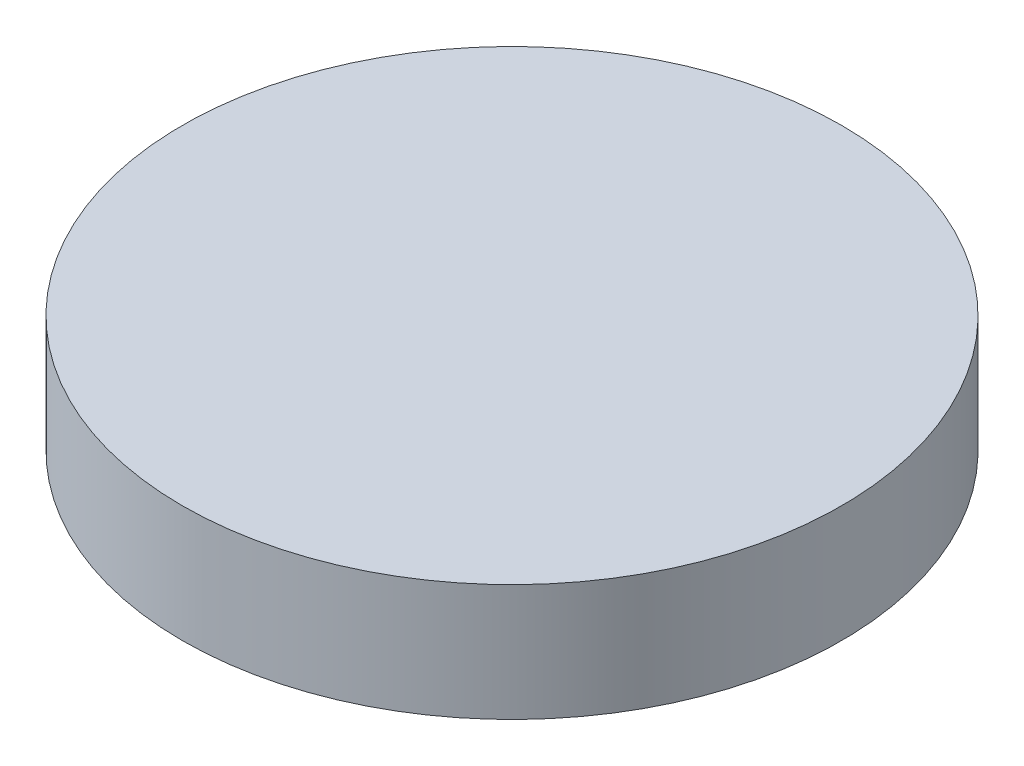
from build123d import *

# Parameters (mm, degrees)
SKETCH1_R           = 40.35
BOSS_EXTRUDE1_DEPTH = 14.3


with BuildPart() as part:
    # Sketch1 → Boss-Extrude1 (new body)
    with BuildSketch(Plane(origin=(0, 0, 0), x_dir=(1, 0, 0), z_dir=(0, 1, 0))):
        with Locations((0, 5.951400749)):
            Circle(SKETCH1_R)
    extrude(amount=BOSS_EXTRUDE1_DEPTH)


solid = part.part
